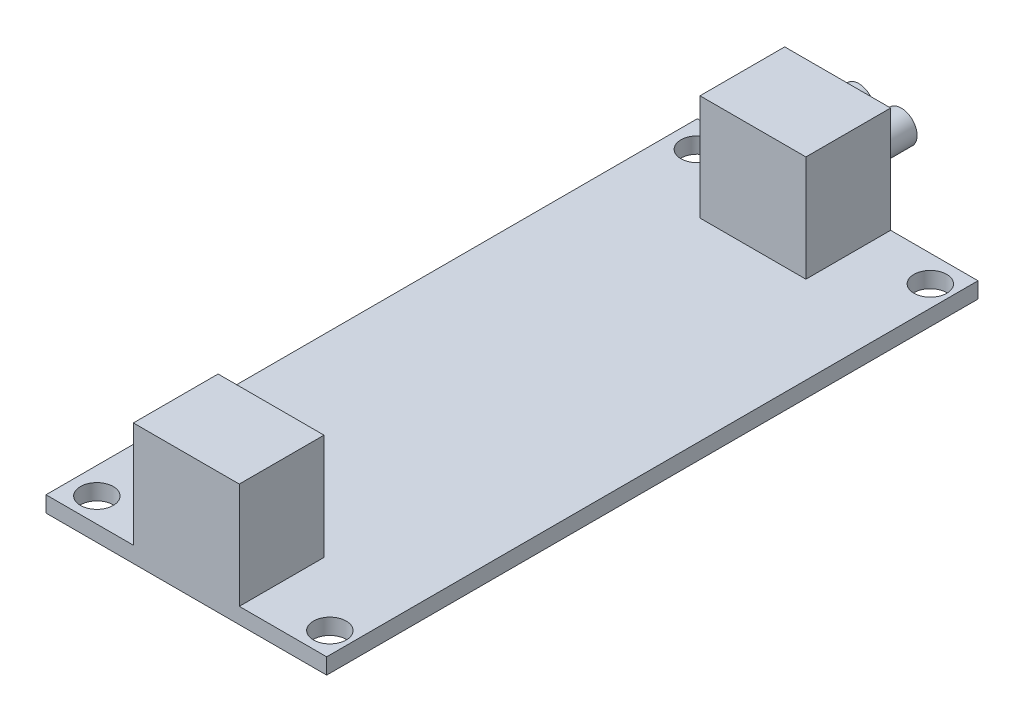
from build123d import *

# Parameters (mm, degrees)
SKIZZE1_W                       = 26.5
SKIZZE1_H                       = 61.5
AUFSATZ_LINEAR_AUSTRAGEN1_DEPTH = 1.5
SKIZZE2_R                       = 1.55
SCHNITT_LINEAR_AUSTRAGEN1_DEPTH = 2.5
SKIZZE3_W                       = 10
SKIZZE3_H                       = 8
AUFSATZ_LINEAR_AUSTRAGEN2_DEPTH = 10
SKIZZE4_R                       = 1.5
AUFSATZ_LINEAR_AUSTRAGEN3_DEPTH = 4


with BuildPart() as part:
    # Skizze1 → Aufsatz-Linear austragen1 (new body)
    with BuildSketch(Plane(origin=(0, 0, 0), x_dir=(1, 0, 0), z_dir=(0, 1, 0))):
        Rectangle(SKIZZE1_W, SKIZZE1_H)
    extrude(amount=AUFSATZ_LINEAR_AUSTRAGEN1_DEPTH)

    # Skizze2 → Schnitt-Linear austragen1 (cut, through all)
    with BuildSketch(Plane(origin=(0, 1.5, 0), x_dir=(1, 0, 0), z_dir=(0, 1, 0))):
        with Locations((-10.75, 28.25)):
            Circle(SKIZZE2_R)
        with Locations((11.25, 28.25)):
            Circle(SKIZZE2_R)
        with Locations((11.25, -28.45)):
            Circle(SKIZZE2_R)
        with Locations((-10.75, -28.45)):
            Circle(SKIZZE2_R)
    extrude(amount=-SCHNITT_LINEAR_AUSTRAGEN1_DEPTH, mode=Mode.SUBTRACT)

    # Skizze3 → Aufsatz-Linear austragen2 (add)
    with BuildSketch(Plane(origin=(0, 1.5, 0), x_dir=(1, 0, 0), z_dir=(0, 1, 0))):
        with Locations((0, -26.75)):
            Rectangle(SKIZZE3_W, SKIZZE3_H)
        with Locations((0, 26.75)):
            Rectangle(SKIZZE3_W, SKIZZE3_H)
    extrude(amount=AUFSATZ_LINEAR_AUSTRAGEN2_DEPTH)

    # Skizze4 → Aufsatz-Linear austragen3 (add)
    with BuildSketch(Plane(origin=(0, 0, -30.75), x_dir=(-1, 0, 0), z_dir=(0, 0, -1))):
        with Locations((-2, 6.5)):
            Circle(SKIZZE4_R)
        with Locations((2, 6.5)):
            Circle(SKIZZE4_R)
    extrude(amount=AUFSATZ_LINEAR_AUSTRAGEN3_DEPTH)


solid = part.part
